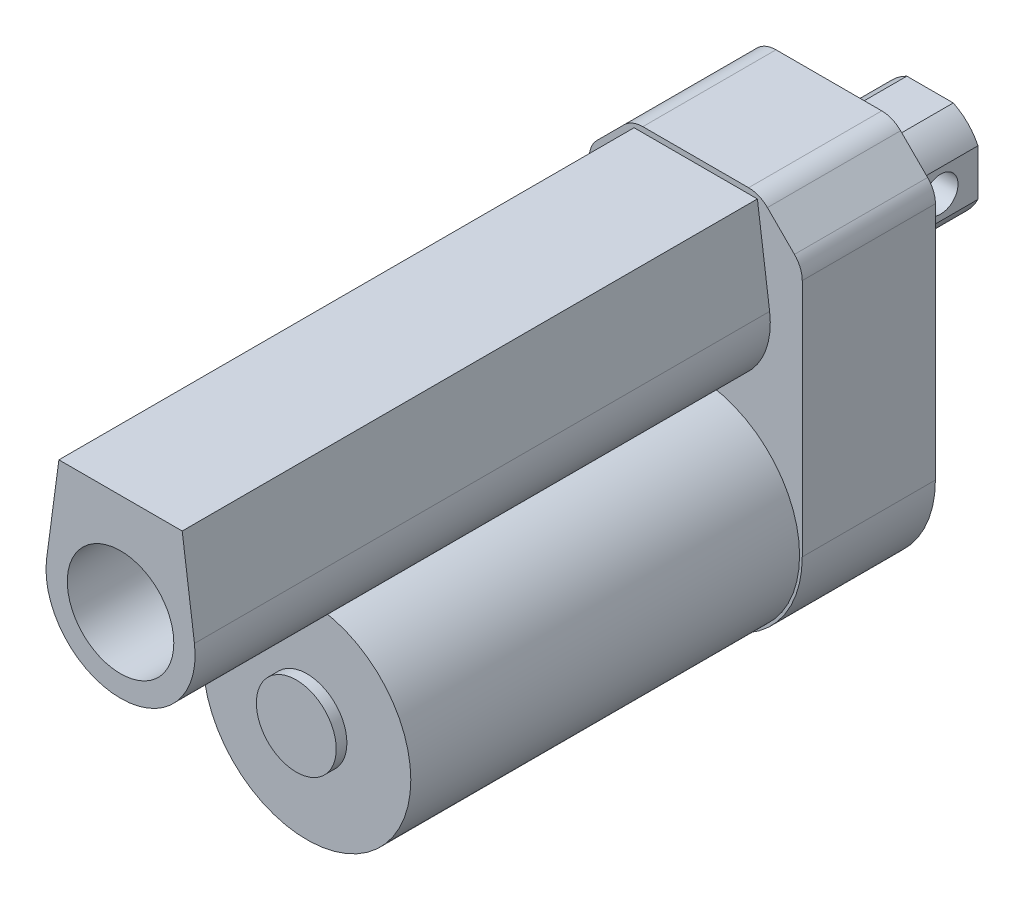
from build123d import *

# Parameters (mm, degrees)
EXTRUDE_1_DEPTH     = 25
SKETCH_2_R          = 19.5
EXTRUDE_2_DEPTH     = 73
SKETCH_3_R          = 7.5
EXTRUDE_3_DEPTH     = 2
EXTRUDE_4_DEPTH     = 108
SKETCH_5_R          = 10
CUT_EXTRUDE_1_DEPTH = 410
EXTRUDE_5_DEPTH     = 19
SKETCH_7_R          = 3.25
CUT_EXTRUDE_2_DEPTH = 94


with BuildPart() as part:
    # 草图1 → 凸台-拉伸1 (new body)
    with BuildSketch(Plane.XY):
        with BuildLine():
            Line((-20, 0), (-20, 44.928932188))
            ThreePointArc((-20, 44.928932188), (-19.619397663, 46.84234935), (-18.535533906, 48.464466094))
            Line((-18.535533906, 48.464466094), (-13.464466094, 53.535533906))
            ThreePointArc((-13.464466094, 53.535533906), (-11.84234935, 54.619397663), (-9.928932188, 55))
            Line((-9.928932188, 55), (9.928932188, 55))
            ThreePointArc((9.928932188, 55), (11.84234935, 54.619397663), (13.464466094, 53.535533906))
            Line((13.464466094, 53.535533906), (18.535533906, 48.464466094))
            ThreePointArc((18.535533906, 48.464466094), (19.619397663, 46.84234935), (20, 44.928932188))
            Line((20, 44.928932188), (20, 0))
            ThreePointArc((20, 0), (0, -20), (-20, 0))
        make_face()
    extrude(amount=EXTRUDE_1_DEPTH)

    # 草图2 → 凸台-拉伸2 (add)
    with BuildSketch(Plane.XY.offset(25)):
        Circle(SKETCH_2_R)
    extrude(amount=EXTRUDE_2_DEPTH)

    # 草图3 → 凸台-拉伸3 (add)
    with BuildSketch(Plane.XY.offset(98)):
        Circle(SKETCH_3_R)
    extrude(amount=EXTRUDE_3_DEPTH)

    # 草图4 → 凸台-拉伸4 (add)
    with BuildSketch(Plane.XY.offset(25)):
        with BuildLine():
            Line((-11.576521962, 54), (-13.87569737, 36.861457087))
            ThreePointArc((-13.87569737, 36.861457087), (0, 21), (13.87569737, 36.861457087))
            Line((13.87569737, 36.861457087), (11.576521962, 54))
            Line((11.576521962, 54), (-11.576521962, 54))
        make_face()
    extrude(amount=EXTRUDE_4_DEPTH)

    # 草图5 → 切除-拉伸1 (cut)
    with BuildSketch(Plane.XY.offset(133)):
        with Locations((0, 35)):
            Circle(SKETCH_5_R)
    extrude(amount=-CUT_EXTRUDE_1_DEPTH, mode=Mode.SUBTRACT)


with BuildPart() as body_2:
    # 草图6 → 凸台-拉伸5 (new body)
    with BuildSketch(Plane(origin=(0, 0, 0), x_dir=(-1, 0, 0), z_dir=(0, 0, -1))):
        with BuildLine():
            Line((-4.358898944, 44), (4.358898944, 44))
            ThreePointArc((4.358898944, 44), (7.071067812, 42.071067812), (9, 39.358898944))
            Line((9, 39.358898944), (9, 30.641101056))
            ThreePointArc((9, 30.641101056), (7.071067812, 27.928932188), (4.358898944, 26))
            Line((4.358898944, 26), (-4.358898944, 26))
            ThreePointArc((-4.358898944, 26), (-7.071067812, 27.928932188), (-9, 30.641101056))
            Line((-9, 30.641101056), (-9, 39.358898944))
            ThreePointArc((-9, 39.358898944), (-7.071067812, 42.071067812), (-4.358898944, 44))
        make_face()
    extrude(amount=EXTRUDE_5_DEPTH)

    # 草图7 → 切除-拉伸2 (cut)
    with BuildSketch(Plane(origin=(9, 0, 0), x_dir=(0, 0, -1), z_dir=(1, 0, 0))):
        with Locations((12, 35)):
            Circle(SKETCH_7_R)
    extrude(amount=-CUT_EXTRUDE_2_DEPTH, mode=Mode.SUBTRACT)


solid = Compound([part.part, body_2.part])
